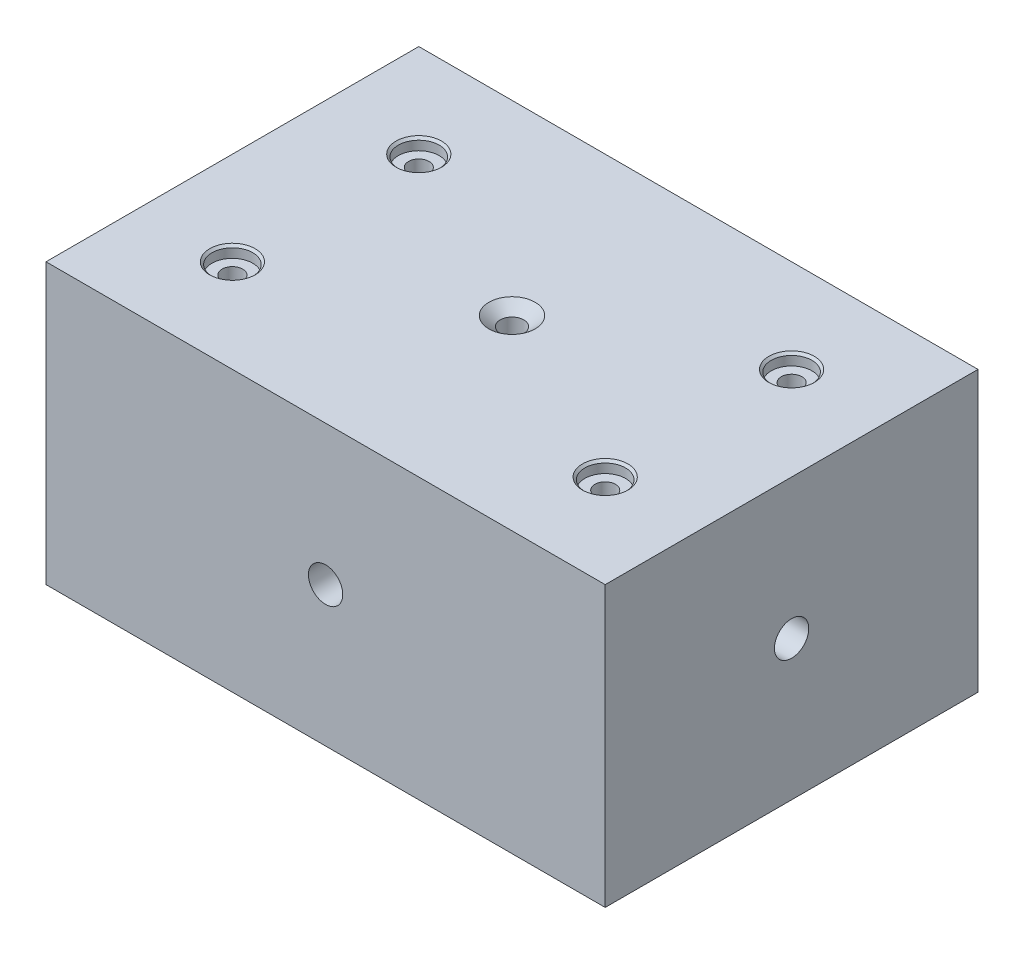
from build123d import *

# Parameters (mm, degrees)
SKETCH1_W                                       = 152.4
SKETCH1_H                                       = 101.6
BOSS_EXTRUDE1_DEPTH                             = 76.2
CBORE_FOR_10_BINDING_HEAD_MACHINE_S_2_COUNT     = 2
CBORE_FOR_10_BINDING_HEAD_MACHINE_S_2_PITCH     = 101.6
CBORE_FOR_10_BINDING_HEAD_MACHINE_S_3_COUNT     = 2
CBORE_FOR_10_BINDING_HEAD_MACHINE_S_3_PITCH     = 113.592253257
CBORE_FOR_10_BINDING_HEAD_MACHINE_S_4_COUNT     = 2
CBORE_FOR_10_BINDING_HEAD_MACHINE_S_4_PITCH     = 50.8
CSK_FOR_M6_FLAT_HEAD_MACHINE_SCREW1_D           = 6.4
CSK_FOR_M6_FLAT_HEAD_MACHINE_SCREW1_DEPTH       = 50.8
CSK_FOR_M6_FLAT_HEAD_MACHINE_SCREW1_CSINK_D     = 12.6
CSK_FOR_M6_FLAT_HEAD_MACHINE_SCREW1_CSINK_ANGLE = 100
CSK_FOR_M6_FLAT_HEAD_MACHINE_SCREW1_TIP         = 1.922753981
F_7_16_14_TAPPED_HOLE1_D                        = 9.3472
F_7_16_14_TAPPED_HOLE1_ON_FACE_2_D              = 9.3472


with BuildPart() as part:
    # Sketch1 → Boss-Extrude1 (new body)
    with BuildSketch(Plane(origin=(0, 0, 0), x_dir=(1, 0, 0), z_dir=(0, 1, 0))):
        Rectangle(SKETCH1_W, SKETCH1_H)
    extrude(amount=BOSS_EXTRUDE1_DEPTH)

    # Sketch7 → CBORE for #10 Binding Head Machine Screw2 (revolve, cut)
    with BuildSketch(Plane(origin=(-50.8, 76.2, -25.4), x_dir=(0, 0, 1), z_dir=(1, 0, 0))):
        Polygon((0, 0), (0, 76.2), (2.8067, 76.2), (2.8067, 3.1242), (5.55625, 3.1242), (5.55625, 0.635), (6.19125, 0), align=None)
    cbore_for_10_binding_head_machine_screw = revolve(axis=Axis((-50.8, 82.55, -25.4), (0, -1, 0)), mode=Mode.SUBTRACT)

    # CBORE for _10 Binding Head Machine S 2: CBORE for #10 Binding Head Machine Screw2 ×2
    with Locations(*[(i * CBORE_FOR_10_BINDING_HEAD_MACHINE_S_2_PITCH, 0, 0) for i in range(1, CBORE_FOR_10_BINDING_HEAD_MACHINE_S_2_COUNT)]):
        add(cbore_for_10_binding_head_machine_screw, mode=Mode.SUBTRACT)

    # CBORE for _10 Binding Head Machine S 3: CBORE for #10 Binding Head Machine Screw2 ×2
    with Locations(*[Vector(0.894427191, 0, 0.447213595) * (i * CBORE_FOR_10_BINDING_HEAD_MACHINE_S_3_PITCH) for i in range(1, CBORE_FOR_10_BINDING_HEAD_MACHINE_S_3_COUNT)]):
        add(cbore_for_10_binding_head_machine_screw, mode=Mode.SUBTRACT)

    # CBORE for _10 Binding Head Machine S 4: CBORE for #10 Binding Head Machine Screw2 ×2
    with Locations(*[(0, 0, i * CBORE_FOR_10_BINDING_HEAD_MACHINE_S_4_PITCH) for i in range(1, CBORE_FOR_10_BINDING_HEAD_MACHINE_S_4_COUNT)]):
        add(cbore_for_10_binding_head_machine_screw, mode=Mode.SUBTRACT)

    # CSK for M6 Flat Head Machine Screw1
    with Locations(Plane(origin=(0, 76.2, 0), x_dir=(1, 0, 0), z_dir=(0, 1, 0))):
        with Locations((0, 0)):
            CounterSinkHole(CSK_FOR_M6_FLAT_HEAD_MACHINE_SCREW1_D / 2, CSK_FOR_M6_FLAT_HEAD_MACHINE_SCREW1_CSINK_D / 2, depth=CSK_FOR_M6_FLAT_HEAD_MACHINE_SCREW1_DEPTH, counter_sink_angle=CSK_FOR_M6_FLAT_HEAD_MACHINE_SCREW1_CSINK_ANGLE)
            with Locations((0, 0, -(CSK_FOR_M6_FLAT_HEAD_MACHINE_SCREW1_DEPTH + CSK_FOR_M6_FLAT_HEAD_MACHINE_SCREW1_TIP / 2))):  # 118° drill point
                Cone(0, CSK_FOR_M6_FLAT_HEAD_MACHINE_SCREW1_D / 2, CSK_FOR_M6_FLAT_HEAD_MACHINE_SCREW1_TIP, mode=Mode.SUBTRACT)

    # 7/16-14 Tapped Hole1 (through all)
    with Locations(Plane(origin=(0, 38.1, 50.8), x_dir=(1, 0, 0), z_dir=(0, 0, 1))):
        with Locations((0, 0)):
            Hole(F_7_16_14_TAPPED_HOLE1_D / 2)

    # 7/16-14 Tapped Hole1 on face 2 (through all)
    with Locations(Plane(origin=(76.2, 38.1, 0), x_dir=(0, 0, 1), z_dir=(1, 0, 0))):
        with Locations((0, 0)):
            Hole(F_7_16_14_TAPPED_HOLE1_ON_FACE_2_D / 2)


solid = part.part
